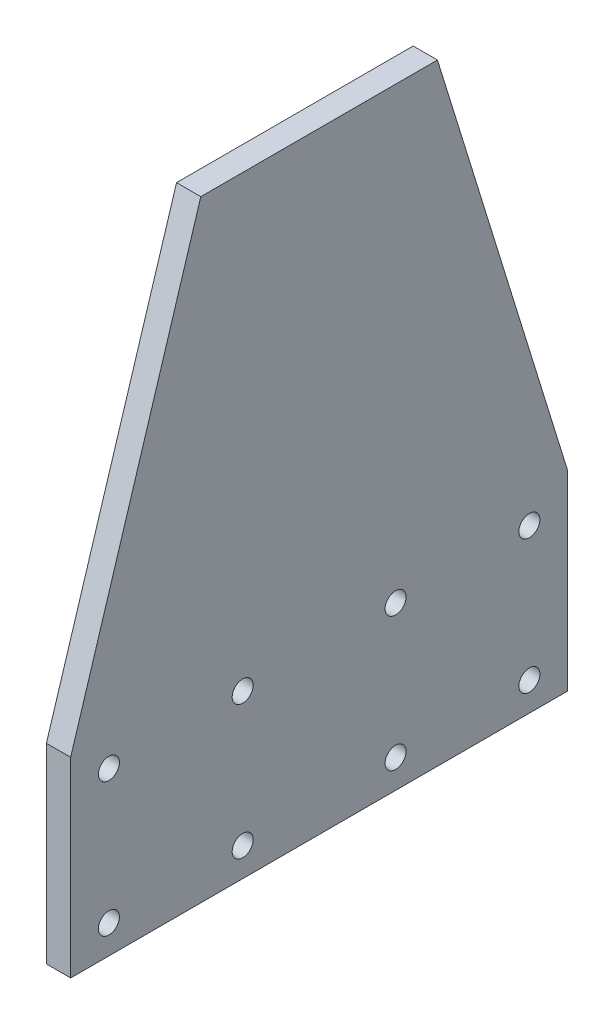
from build123d import *

# Parameters (mm, degrees)
BOSS_EXTRUDE1_DEPTH = 6.35
SKETCH3_R           = 2.75
CUT_EXTRUDE1_DEPTH  = 7.35


with BuildPart() as part:
    # Sketch2 → Boss-Extrude1 (new body)
    with BuildSketch(Plane(origin=(0, 0, 0), x_dir=(0, 0, -1), z_dir=(1, 0, 0))):
        Polygon((34.047619048, 160), (95.952380952, 160), (130, 50), (130, 0), (0, 0), (0, 50), align=None)
    extrude(amount=BOSS_EXTRUDE1_DEPTH)

    # Sketch3 → Cut-Extrude1 (cut, through all)
    with BuildSketch(Plane(origin=(6.35, 0, 0), x_dir=(0, 0, -1), z_dir=(1, 0, 0))):
        with Locations((10, 42.5)):
            Circle(SKETCH3_R)
        with Locations((45, 42.5)):
            Circle(SKETCH3_R)
        with Locations((10, 7.5)):
            Circle(SKETCH3_R)
        with Locations((45, 7.5)):
            Circle(SKETCH3_R)
        with Locations((120, 7.5)):
            Circle(SKETCH3_R)
        with Locations((85, 7.5)):
            Circle(SKETCH3_R)
        with Locations((85, 42.5)):
            Circle(SKETCH3_R)
        with Locations((120, 42.5)):
            Circle(SKETCH3_R)
    extrude(amount=-CUT_EXTRUDE1_DEPTH, mode=Mode.SUBTRACT)


solid = part.part
